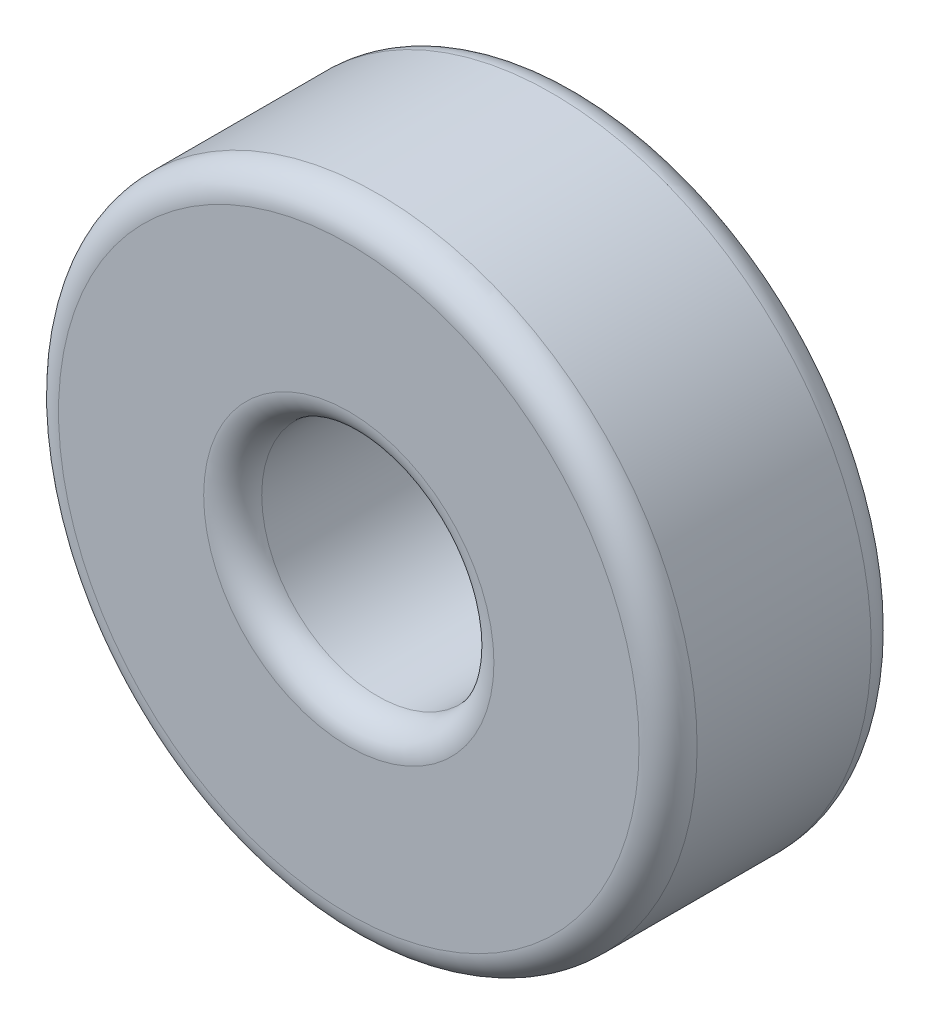
from build123d import *

# Parameters (mm, degrees)
ESQUISSE1_R          = 5.5
ESQUISSE1_R_2        = 2
BASE_EXTRUSION_DEPTH = 4
CONG_1_R             = 0.5


with BuildPart() as part:
    # Esquisse1 → Base-Extrusion (new body)
    with BuildSketch(Plane.XY):
        Circle(ESQUISSE1_R)
        Circle(ESQUISSE1_R_2, mode=Mode.SUBTRACT)
    extrude(amount=BASE_EXTRUSION_DEPTH)

    # Congé1
    cong_1_edges = [part.edges().sort_by_distance(p)[0] for p in [
        (-5.5, 0, 0),
        (-5.5, 0, 4),
        (-2, 0, 0),
        (-2, 0, 4),
    ]]
    fillet(cong_1_edges, radius=CONG_1_R)


solid = part.part
